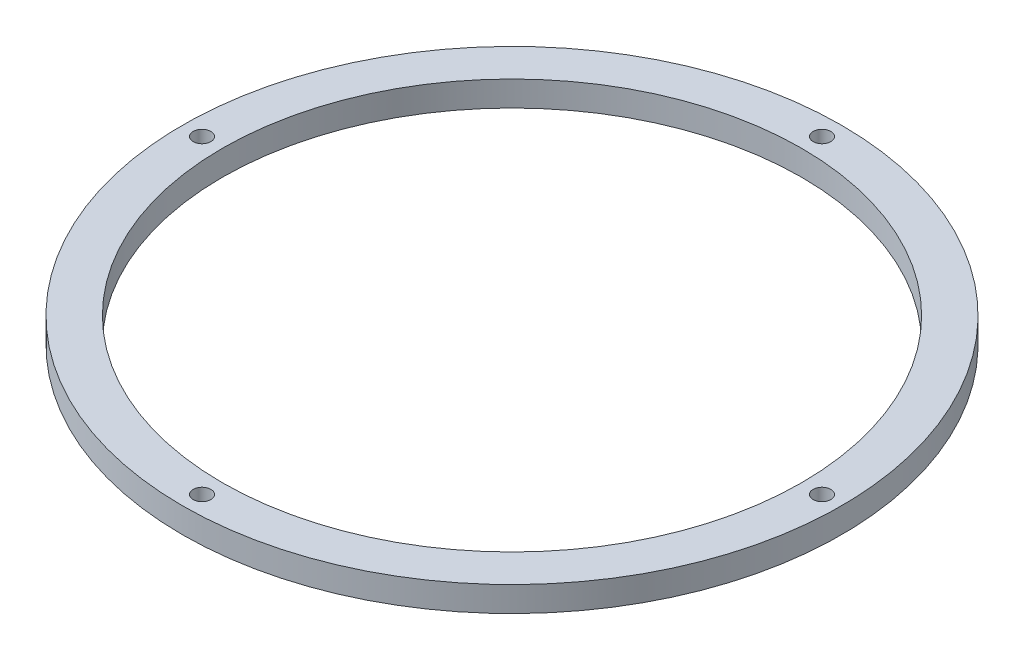
from build123d import *

# Parameters (mm, degrees)
SKETCH1_R           = 111.5
SKETCH1_R_2         = 98
BOSS_EXTRUDE1_DEPTH = 8.5
SKETCH2_R           = 3
CUT_EXTRUDE1_DEPTH  = 9.5


with BuildPart() as part:
    # Sketch1 → Boss-Extrude1 (new body)
    with BuildSketch(Plane(origin=(0, 0, 0), x_dir=(1, 0, 0), z_dir=(0, 1, 0))):
        Circle(SKETCH1_R)
        Circle(SKETCH1_R_2, mode=Mode.SUBTRACT)
    extrude(amount=BOSS_EXTRUDE1_DEPTH)

    # Sketch2 → Cut-Extrude1 (cut, through all)
    with BuildSketch(Plane(origin=(0, 8.5, 0), x_dir=(1, 0, 0), z_dir=(0, 1, 0))):
        with Locations((0, 104.875)):
            Circle(SKETCH2_R)
        with Locations((-104.875, 0)):
            Circle(SKETCH2_R)
        with Locations((104.875, 0)):
            Circle(SKETCH2_R)
        with Locations((0, -104.875)):
            Circle(SKETCH2_R)
    extrude(amount=-CUT_EXTRUDE1_DEPTH, mode=Mode.SUBTRACT)


solid = part.part
